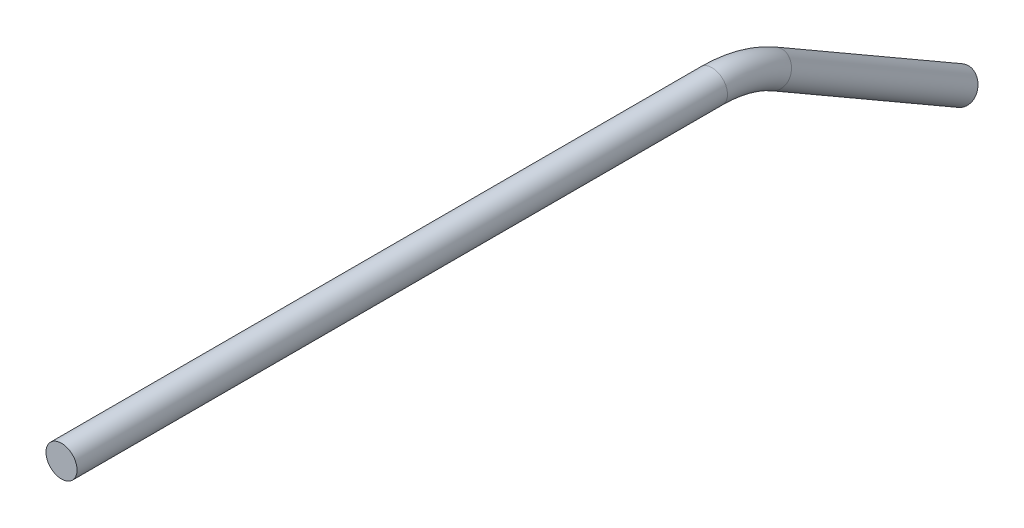
from build123d import *

# Parameters (mm, degrees)
SKETCH2_R = 3.175


with BuildPart() as part:
    # Sweep1: sweep along a path in Sketch4
    with BuildLine(Plane(origin=(0, 0, 0), x_dir=(0, 0, -1), z_dir=(1, 0, 0))) as sweep1_path:
        Line((0, 0), (132.894090512, 0))
        ThreePointArc((132.894090512, 0), (139.468094258, -0.865484012), (145.594090512, -3.402954744))
        Line((145.594090512, -3.402954744), (183.694090512, -25.4))
    # Sketch2 → Sweep1 (sweep)
    with BuildSketch(Plane.XY):
        Circle(SKETCH2_R)
    sweep(path=sweep1_path.line)


solid = part.part
